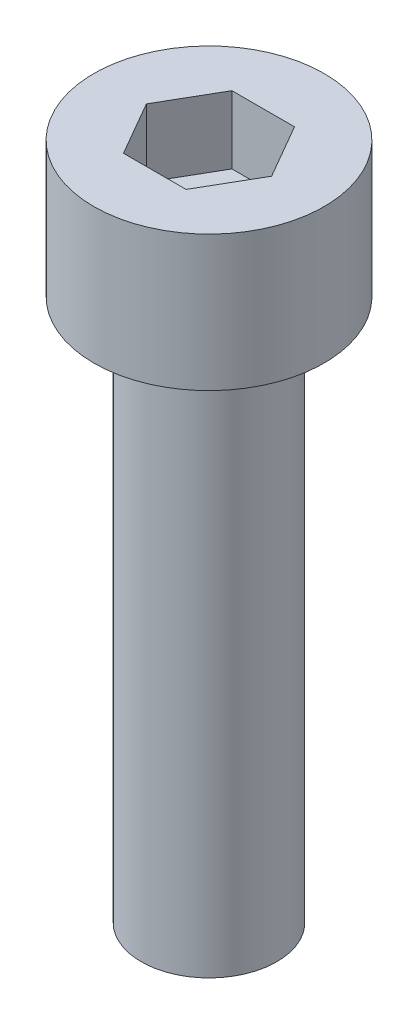
from build123d import *

# Parameters (mm, degrees)
SKETCH_1_R          = 4.25
EXTRUDE_1_DEPTH     = 5
CUT_EXTRUDE_1_DEPTH = 2.5
SKETCH_3_R          = 2.5
EXTRUDE_2_DEPTH     = 20


with BuildPart() as part:
    # 草图1 → 凸台-拉伸1 (new body)
    with BuildSketch(Plane(origin=(0, 0, 0), x_dir=(1, 0, 0), z_dir=(0, 1, 0))):
        Circle(SKETCH_1_R)
    extrude(amount=EXTRUDE_1_DEPTH)

    # 草图2 → 切除-拉伸1 (cut)
    with BuildSketch(Plane(origin=(0, 5, 0), x_dir=(1, 0, 0), z_dir=(0, 1, 0))):
        Polygon((2.309401077, 0), (1.154700538, 2), (-1.154700538, 2), (-2.309401077, 0), (-1.154700538, -2), (1.154700538, -2), align=None)
    extrude(amount=-CUT_EXTRUDE_1_DEPTH, mode=Mode.SUBTRACT)

    # 草图3 → 凸台-拉伸2 (add)
    with BuildSketch(Plane.XZ):
        Circle(SKETCH_3_R)
    extrude(amount=EXTRUDE_2_DEPTH)


solid = part.part
